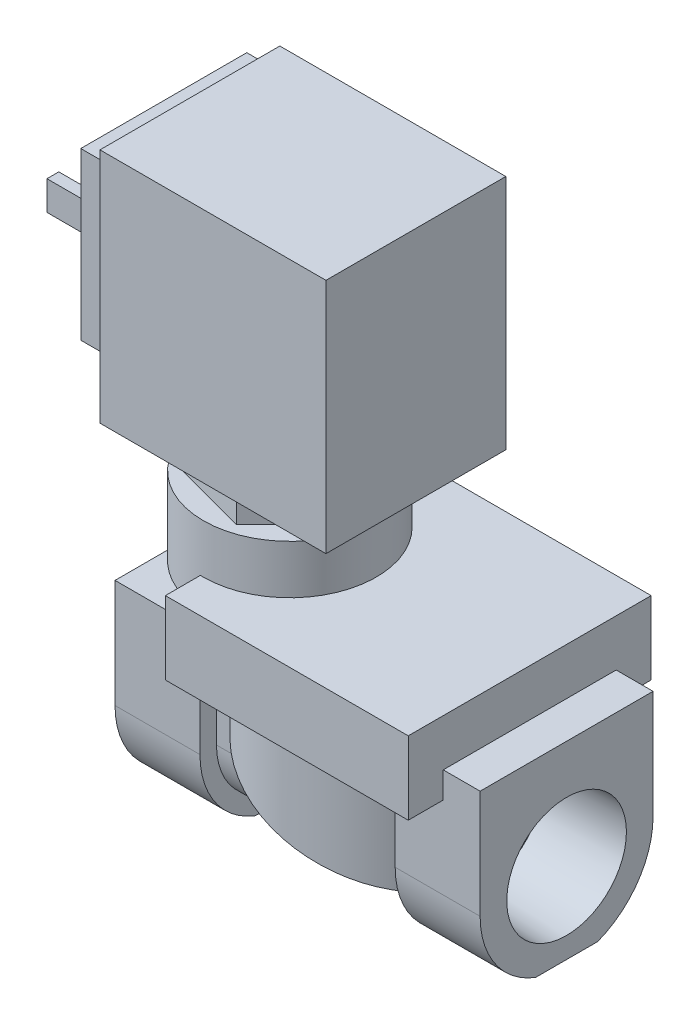
from build123d import *

# Parameters (mm, degrees)
SKETCH1_R                = 18.0086
BOSS_EXTRUDE1_DEPTH      = 20.9296
CUT_EXTRUDE1_DEPTH       = 19.0086
CUT_EXTRUDE1_DEPTH_BACK  = 19.0086
BOSS_EXTRUDE2_DEPTH      = 16.129
BOSS_EXTRUDE3_DEPTH      = 14.0335
SKETCH6_W                = 40.132
SKETCH6_H                = 40.132
BOSS_EXTRUDE4_DEPTH      = 12.0777
SKETCH7_R                = 14.2875
BOSS_EXTRUDE5_DEPTH      = 8.0772
BOSS_EXTRUDE5_DEPTH_BACK = 4.826
BOSS_EXTRUDE6_DEPTH      = 5.9817
SKETCH11_W               = 41.656
SKETCH11_H               = 29.718
BOSS_EXTRUDE7_DEPTH      = 39.116
SKETCH12_W               = 29.718
SKETCH12_H               = 39.116
SKETCH12_W_2             = 27.432
SKETCH12_H_2             = 27.432
CUT_EXTRUDE2_DEPTH       = 4.318
BOSS_EXTRUDE8_DEPTH      = 10.16


with BuildPart() as part:
    # Sketch1 → Boss-Extrude1 (new body)
    with BuildSketch(Plane(origin=(0, 0, 0), x_dir=(1, 0, 0), z_dir=(0, 1, 0))):
        Circle(SKETCH1_R)
    extrude(amount=-BOSS_EXTRUDE1_DEPTH)

    # Sketch2 → Cut-Extrude1 (cut, two sides)
    with BuildSketch(Plane.XY) as cut_extrude1_sk:
        Polygon((-18.0086, -8.382), (18.0086, -20.9296), (-18.0086, -20.9296), align=None)
    extrude(amount=CUT_EXTRUDE1_DEPTH, mode=Mode.SUBTRACT)
    extrude(cut_extrude1_sk.sketch, amount=-CUT_EXTRUDE1_DEPTH_BACK, mode=Mode.SUBTRACT)

    # Sketch3 → Boss-Extrude2 (add, symmetric)
    with BuildSketch(Plane(origin=(0, 0, 0), x_dir=(0, 0, -1), z_dir=(1, 0, 0))):
        with BuildLine():
            Line((-11.557, 0), (-11.557, -13.589))
            ThreePointArc((-11.557, -13.589), (0, -25.146), (11.557, -13.589))
            Line((11.557, -13.589), (11.557, 0))
            Line((11.557, 0), (-11.557, 0))
        make_face()
    extrude(amount=BOSS_EXTRUDE2_DEPTH, both=True)

    # Sketch5 → Boss-Extrude3 (add)
    with BuildSketch(Plane.ZY.offset(16.129)):
        with BuildLine():
            Line((-14.2875, 4.318), (-14.2875, -13.589))
            ThreePointArc((-14.2875, -13.589), (-11.777489603, -21.677472965), (-5.129369479, -26.924))
            Line((-5.129369479, -26.924), (5.129369479, -26.924))
            ThreePointArc((5.129369479, -26.924), (11.777489603, -21.677472965), (14.2875, -13.589))
            Line((14.2875, -13.589), (14.2875, 4.318))
            Line((14.2875, 4.318), (-14.2875, 4.318))
        make_face()
    boss_extrude3 = extrude(amount=BOSS_EXTRUDE3_DEPTH)

    # Mirror1: Boss-Extrude3 across plane
    add(boss_extrude3.mirror(Plane(origin=(0, 0, 0), x_dir=(0, 0, 1), z_dir=(1, 0, 0))))

    # Sketch6 → Boss-Extrude4 (add)
    with BuildSketch(Plane(origin=(0, 0, 0), x_dir=(1, 0, 0), z_dir=(0, 1, 0))):
        with Locations((4.0005, 0)):
            Rectangle(SKETCH6_W, SKETCH6_H)
    extrude(amount=BOSS_EXTRUDE4_DEPTH)

    # Sketch7 → Boss-Extrude5 (add, two sides)
    with BuildSketch(Plane(origin=(0, 12.0777, 0), x_dir=(1, 0, 0), z_dir=(0, 1, 0))) as boss_extrude5_sk:
        with Locations((-15.56738583, 0)):
            Circle(SKETCH7_R)
    extrude(amount=BOSS_EXTRUDE5_DEPTH)
    extrude(boss_extrude5_sk.sketch, amount=-BOSS_EXTRUDE5_DEPTH_BACK)

    # Sketch8 → 1/2 NPT Tapped Hole1 (revolve, cut)
    with BuildSketch(Plane(origin=(30.1625, -13.589, 0), x_dir=(0, 0, -1), z_dir=(0, 1, 0))):
        Polygon((0, 0), (0, 28.003563693), (8.9281, 22.63902), (8.9281, 13.57122), (9.479720499, 13.57122), (9.886061, 0), align=None)
    f_1_2_npt_tapped_hole1 = revolve(axis=Axis((36.5125, -13.589, 0), (-1, 0, 0)), mode=Mode.SUBTRACT)

    # Mirror2: 1/2 NPT Tapped Hole1 across plane
    add(f_1_2_npt_tapped_hole1.mirror(Plane(origin=(0, 0, 0), x_dir=(0, 0, 1), z_dir=(1, 0, 0))), mode=Mode.SUBTRACT)

    # Sketch10 → Boss-Extrude6 (add)
    with BuildSketch(Plane(origin=(0, 20.1549, 0), x_dir=(1, 0, 0), z_dir=(0, 1, 0))):
        Polygon((-6.716522972, 8.880967834), (-18.833098156, 12.105555998), (-27.683961014, 3.224588164), (-24.418248689, -8.880967834), (-12.301673505, -12.105555998), (-3.450810647, -3.224588164), align=None)
    extrude(amount=BOSS_EXTRUDE6_DEPTH)

    # Sketch11 → Boss-Extrude7 (add)
    with BuildSketch(Plane(origin=(0, 26.1366, 0), x_dir=(1, 0, 0), z_dir=(0, 1, 0))):
        with Locations((-15.56738583, 0)):
            Rectangle(SKETCH11_W, SKETCH11_H)
    extrude(amount=BOSS_EXTRUDE7_DEPTH)

    # Sketch12 → Cut-Extrude2 (cut)
    with BuildSketch(Plane.ZY.offset(36.39538583)):
        with Locations((0, 45.6946)):
            Rectangle(SKETCH12_W, SKETCH12_H)
        with Locations((0, 48.9966)):
            Rectangle(SKETCH12_W_2, SKETCH12_H_2, mode=Mode.SUBTRACT)
    extrude(amount=-CUT_EXTRUDE2_DEPTH, mode=Mode.SUBTRACT)

    # Sketch13 → Boss-Extrude8 (add)
    with BuildSketch(Plane.ZY.offset(36.39538583)):
        Polygon((-7.1882, 51.0286), (-9.144, 51.0286), (-9.144, 46.2026), (-7.1882, 46.2026), (-7.1882, 46.9646), (-8.382, 46.9646), (-8.382, 50.2666), (-7.1882, 50.2666), align=None)
        Polygon((7.1882, 46.9646), (7.1882, 46.2026), (9.144, 46.2026), (9.144, 51.0286), (7.1882, 51.0286), (7.1882, 50.2666), (8.382, 50.2666), (8.382, 46.9646), align=None)
    extrude(amount=BOSS_EXTRUDE8_DEPTH)


solid = part.part
